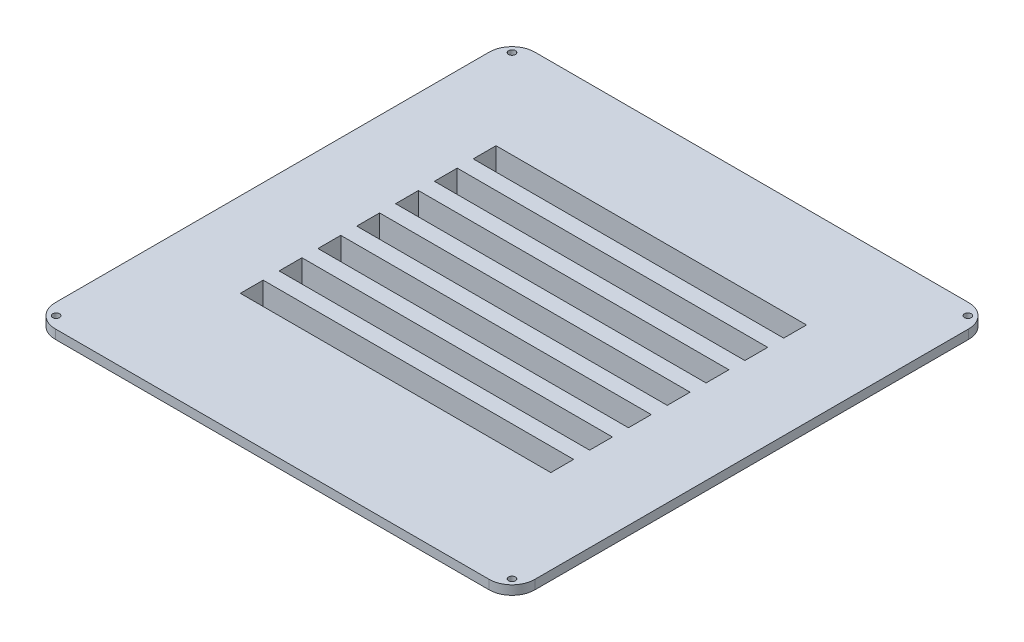
from build123d import *

# Parameters (mm, degrees)
SKETCH1_W           = 210
SKETCH1_H           = 210
MAINEXTRUDE_DEPTH   = 4
SKETCH1_6_R         = 1.5
SCREWHOLES_DEPTH    = 4
ROUNDEDCORNERS_R    = 10
SKETCH4_W           = 140
SKETCH4_H           = 14
SKETCH4_W_2         = 136
SKETCH4_H_2         = 10
TRENCH_WALLS_DEPTH  = 10
SKETCH3_W           = 136
SKETCH3_H           = 10
TRENCH_DEPTH        = 12
SKETCH6_W           = 140
SKETCH6_H           = 14
TRENCH_BOTTOM_DEPTH = 2


with BuildPart() as part:
    # Sketch1 → MainExtrude (new body)
    with BuildSketch(Plane(origin=(0, 0, 0), x_dir=(1, 0, 0), z_dir=(0, 1, 0))):
        Rectangle(SKETCH1_W, SKETCH1_H)
    extrude(amount=MAINEXTRUDE_DEPTH)

    # Sketch1_6 → ScrewHoles (cut)
    with BuildSketch(Plane(origin=(0, 0, 0), x_dir=(1, 0, 0), z_dir=(0, 1, 0))):
        with Locations((-99.833273811, 99.833273811)):
            Circle(SKETCH1_6_R)
        with Locations((-99.833273811, -99.833273811)):
            Circle(SKETCH1_6_R)
        with Locations((99.833273811, -99.833273811)):
            Circle(SKETCH1_6_R)
        with Locations((99.833273811, 99.833273811)):
            Circle(SKETCH1_6_R)
    extrude(amount=SCREWHOLES_DEPTH, mode=Mode.SUBTRACT)

    # RoundedCorners
    roundedcorners_edges = [part.edges().sort_by_distance(p)[0] for p in [
        (-105, 2, -105),
        (-105, 2, 105),
        (105, 2, 105),
        (105, 2, -105),
    ]]
    fillet(roundedcorners_edges, radius=ROUNDEDCORNERS_R)

    # Sketch4 → Trench Walls (add)
    with BuildSketch(Plane(origin=(0, 0, 0), x_dir=(1, 0, 0), z_dir=(0, 1, 0))):
        with Locations((0, 56)):
            Rectangle(SKETCH4_W, SKETCH4_H)
        with Locations((0, 56)):
            Rectangle(SKETCH4_W_2, SKETCH4_H_2, mode=Mode.SUBTRACT)
        with Locations((0, 39)):
            Rectangle(SKETCH4_W, SKETCH4_H)
        with Locations((0, 39)):
            Rectangle(SKETCH4_W_2, SKETCH4_H_2, mode=Mode.SUBTRACT)
        with Locations((0, 22)):
            Rectangle(SKETCH4_W, SKETCH4_H)
        with Locations((0, 22)):
            Rectangle(SKETCH4_W_2, SKETCH4_H_2, mode=Mode.SUBTRACT)
        with Locations((0, 5)):
            Rectangle(SKETCH4_W, SKETCH4_H)
        with Locations((0, 5)):
            Rectangle(SKETCH4_W_2, SKETCH4_H_2, mode=Mode.SUBTRACT)
        with Locations((0, -12)):
            Rectangle(SKETCH4_W, SKETCH4_H)
        with Locations((0, -12)):
            Rectangle(SKETCH4_W_2, SKETCH4_H_2, mode=Mode.SUBTRACT)
        with Locations((0, -29)):
            Rectangle(SKETCH4_W, SKETCH4_H)
        with Locations((0, -29)):
            Rectangle(SKETCH4_W_2, SKETCH4_H_2, mode=Mode.SUBTRACT)
        with Locations((0, -46)):
            Rectangle(SKETCH4_W, SKETCH4_H)
        with Locations((0, -46)):
            Rectangle(SKETCH4_W_2, SKETCH4_H_2, mode=Mode.SUBTRACT)
    extrude(amount=-TRENCH_WALLS_DEPTH)

    # Sketch3 → Trench (cut)
    with BuildSketch(Plane(origin=(0, 0, 0), x_dir=(1, 0, 0), z_dir=(0, 1, 0))):
        with Locations((0, 56)):
            Rectangle(SKETCH3_W, SKETCH3_H)
        with Locations((0, 39)):
            Rectangle(SKETCH3_W, SKETCH3_H)
        with Locations((0, 22)):
            Rectangle(SKETCH3_W, SKETCH3_H)
        with Locations((0, 5)):
            Rectangle(SKETCH3_W, SKETCH3_H)
        with Locations((0, -12)):
            Rectangle(SKETCH3_W, SKETCH3_H)
        with Locations((0, -29)):
            Rectangle(SKETCH3_W, SKETCH3_H)
        with Locations((0, -46)):
            Rectangle(SKETCH3_W, SKETCH3_H)
    extrude(amount=TRENCH_DEPTH, mode=Mode.SUBTRACT)

    # Sketch6 → Trench Bottom (add)
    with BuildSketch(Plane.XZ.offset(10)):
        with Locations((0, -56)):
            Rectangle(SKETCH6_W, SKETCH6_H)
        with Locations((0, -39)):
            Rectangle(SKETCH6_W, SKETCH6_H)
        with Locations((0, -22)):
            Rectangle(SKETCH6_W, SKETCH6_H)
        with Locations((0, -5)):
            Rectangle(SKETCH6_W, SKETCH6_H)
        with Locations((0, 12)):
            Rectangle(SKETCH6_W, SKETCH6_H)
        with Locations((0, 29)):
            Rectangle(SKETCH6_W, SKETCH6_H)
        with Locations((0, 46)):
            Rectangle(SKETCH6_W, SKETCH6_H)
    extrude(amount=TRENCH_BOTTOM_DEPTH)


solid = part.part
